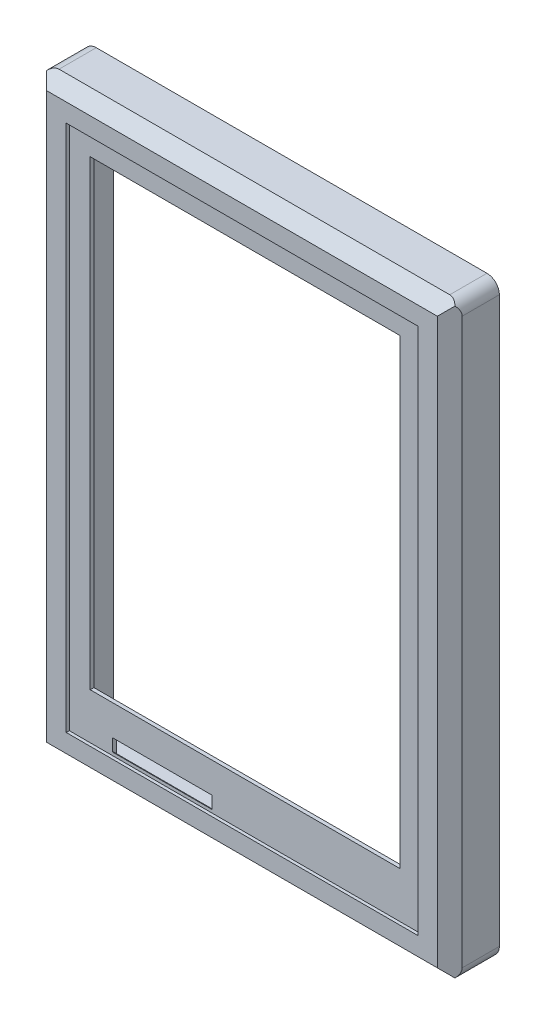
from build123d import *

# Parameters (mm, degrees)
SKIZZE1_W                        = 67
SKIZZE1_H                        = 95
AUFSATZ_LINEAR_AUSTRAGEN1_DEPTH  = 8
SKIZZE2_W                        = 56.7
SKIZZE2_H                        = 85.1
SCHNITT_LINEAR_AUSTRAGEN1_DEPTH  = 0.5
SCHNITT_LINEAR_START             = -7.5
SKIZZE3_W                        = 49.96
SKIZZE3_H                        = 74.44
SCHNITT_LINEAR_AUSTRAGEN2_DEPTH  = 7.5
SCHNITT_LINEAR_AUSTRAGEN3_REACH  = 9.5
SKIZZE4_W                        = 16
SKIZZE4_H                        = 2
SKIZZE5_W                        = 56.8
SKIZZE5_H                        = 85.3
SCHNITT_LINEAR_AUSTRAGEN4_DEPTH  = 6.9
FASE1_SIZE                       = 2
FASE2_SIZE                       = 0.5
SKIZZE8_W                        = 56.8
SKIZZE8_H                        = 3
SCHNITT_LINEAR_AUSTRAGEN5_DEPTH  = 2
SKIZZE10_W                       = 56.8
SKIZZE10_H                       = 1.5
AUFSATZ_LINEAR_AUSTRAGEN2_DEPTH  = 85.3
SCHNITT_LINEAR_AUSTRAGEN6_REACH  = 7.6
SKIZZE12_W                       = 56.8
SKIZZE12_H                       = 82.3
VERRUNDUNG2_R                    = 2
FASE3_SIZE                       = 3
FASE3_SIZE2                      = 0.803847577
SCHNITT_LINEAR_AUSTRAGEN9_DEPTH  = 3
FASE8_SIZE                       = 0.3
SKIZZE18_W                       = 1.65
SKIZZE18_H                       = 4.4
SCHNITT_LINEAR_AUSTRAGEN10_DEPTH = 4.1
AUFSATZ_LINEAR_START             = 1.65
SKIZZE20_R                       = 1.75
AUFSATZ_LINEAR_AUSTRAGEN7_DEPTH  = 4
SCHNITT_LINEAR_START_2           = -1
SKIZZE21_R                       = 1.05
SCHNITT_LINEAR_AUSTRAGEN12_DEPTH = 6.65
LINEARES_MUSTER1_COUNT           = 2
LINEARES_MUSTER1_PITCH           = 68.8
LINEARES_START                   = 1.65
LINEARES_MUSTER1_COPY_1_SKETCH_R = 1.75
LINEARES_MUSTER1_COPY_1_DEPTH    = 4
LINEARES_START_2                 = -1
LINEARES_MUSTER1_COPY_2_SKETCH_R = 1.05
LINEARES_MUSTER1_COPY_2_DEPTH    = 6.65
LINEARES_MUSTER1_COPY_3_SKETCH_W = 1.65
LINEARES_MUSTER1_COPY_3_SKETCH_H = 4.4
LINEARES_MUSTER1_COPY_3_DEPTH    = 4.1


with BuildPart() as part:
    # Skizze1 → Aufsatz-Linear austragen1 (new body)
    with BuildSketch(Plane.XY):
        with Locations((33.5, 47.5)):
            Rectangle(SKIZZE1_W, SKIZZE1_H)
    extrude(amount=AUFSATZ_LINEAR_AUSTRAGEN1_DEPTH)

    # Skizze2 → Schnitt-Linear austragen1 (cut)
    with BuildSketch(Plane.XY.offset(8)):
        with Locations((33.5, 47.5)):
            Rectangle(SKIZZE2_W, SKIZZE2_H)
    extrude(amount=-SCHNITT_LINEAR_AUSTRAGEN1_DEPTH, mode=Mode.SUBTRACT)

    # Skizze3 → Schnitt-Linear austragen2 (cut)
    with BuildSketch(Plane.XY.offset(7.5).offset(SCHNITT_LINEAR_START)):
        with Locations((33.5, 49.57)):
            Rectangle(SKIZZE3_W, SKIZZE3_H)
    extrude(amount=SCHNITT_LINEAR_AUSTRAGEN2_DEPTH, mode=Mode.SUBTRACT)

    # Skizze4 → Schnitt-Linear austragen3 (cut, up to next)
    with BuildSketch(Plane.XY.offset(7.5), mode=Mode.PRIVATE) as schnitt_linear_austragen3_sk1:
        with Locations((20.15, 6.45)):
            Rectangle(SKIZZE4_W, SKIZZE4_H)
    schnitt_linear_austragen3_tool1 = extrude(schnitt_linear_austragen3_sk1.sketch, amount=-SCHNITT_LINEAR_AUSTRAGEN3_REACH, mode=Mode.PRIVATE) & part.part
    add(schnitt_linear_austragen3_tool1.solids().sort_by_distance((20.15, 6.45, 7.5))[0], mode=Mode.SUBTRACT)

    # Skizze5 → Schnitt-Linear austragen4 (cut)
    with BuildSketch(Plane(origin=(0, 0, 0), x_dir=(-1, 0, 0), z_dir=(0, 0, -1))):
        with Locations((-33.5, 47.5)):
            Rectangle(SKIZZE5_W, SKIZZE5_H)
    extrude(amount=-SCHNITT_LINEAR_AUSTRAGEN4_DEPTH, mode=Mode.SUBTRACT)

    # Fase1
    fase1_edges = [part.edges().sort_by_distance(p)[0] for p in [
        (67, 47.5, 8),
        (33.5, 95, 8),
        (0, 47.5, 8),
        (33.5, 0, 8),
    ]]
    chamfer(fase1_edges, length=FASE1_SIZE)

    # Fase2
    fase2_edges = [part.edges().sort_by_distance(p)[0] for p in [
        (20.15, 5.45, 6.9),
    ]]
    chamfer(fase2_edges, length=FASE2_SIZE)

    # Skizze8 → Schnitt-Linear austragen5 (cut)
    with BuildSketch(Plane.XZ.offset(-90.15)):
        with Locations((33.5, 5.4)):
            Rectangle(SKIZZE8_W, SKIZZE8_H)
    extrude(amount=-SCHNITT_LINEAR_AUSTRAGEN5_DEPTH, mode=Mode.SUBTRACT)

    # Skizze10 → Aufsatz-Linear austragen2 (add)
    with BuildSketch(Plane.XZ.offset(-90.15)):
        with Locations((33.5, 3.15)):
            Rectangle(SKIZZE10_W, SKIZZE10_H)
    extrude(amount=AUFSATZ_LINEAR_AUSTRAGEN2_DEPTH)

    # Skizze12 → Schnitt-Linear austragen6 (cut, up to next)
    with BuildSketch(Plane(origin=(0, 0, 2.4), x_dir=(-1, 0, 0), z_dir=(0, 0, -1)), mode=Mode.PRIVATE) as schnitt_linear_austragen6_sk1:
        with Locations((-33.5, 47.5)):
            Rectangle(SKIZZE12_W, SKIZZE12_H)
    schnitt_linear_austragen6_tool1 = extrude(schnitt_linear_austragen6_sk1.sketch, amount=-SCHNITT_LINEAR_AUSTRAGEN6_REACH, mode=Mode.PRIVATE) & part.part
    add(schnitt_linear_austragen6_tool1.solids().sort_by_distance((33.5, 47.5, 2.4))[0], mode=Mode.SUBTRACT)

    # Verrundung2
    verrundung2_edges = [part.edges().sort_by_distance(p)[0] for p in [
        (0, 0, 3),
        (0, 95, 3),
        (67, 0, 3),
        (67, 95, 3),
    ]]
    fillet(verrundung2_edges, radius=VERRUNDUNG2_R)

    # Fase3
    fase3_edges = [part.edges().sort_by_distance(p)[0] for p in [
        (33.5, 88.65, 3.9),
    ]]
    fase3_side = [part.faces().sort_by_distance(p)[0] for p in [
        (33.5, 90.4, 3.9),
    ]]
    chamfer(fase3_edges, length=FASE3_SIZE, length2=FASE3_SIZE2, reference=fase3_side[0])

    # Skizze14 → Schnitt-Linear austragen9 (cut)
    with BuildSketch(Plane(origin=(0, 0, 0), x_dir=(-1, 0, 0), z_dir=(0, 0, -1))):
        with BuildLine():
            Line((-64, 94), (-3, 94))
            ThreePointArc((-3, 94), (-1.585786438, 93.414213562), (-1, 92))
            Line((-1, 92), (-1, 3))
            ThreePointArc((-1, 3), (-1.585786438, 1.585786438), (-3, 1))
            Line((-3, 1), (-64, 1))
            ThreePointArc((-64, 1), (-65.414213562, 1.585786438), (-66, 3))
            Line((-66, 3), (-66, 92))
            ThreePointArc((-66, 92), (-65.414213562, 93.414213562), (-64, 94))
        make_face()
        with BuildLine():
            ThreePointArc((-64.8, 4.2), (-64.214213562, 2.785786438), (-62.8, 2.2))
            Line((-62.8, 2.2), (-4.2, 2.2))
            ThreePointArc((-4.2, 2.2), (-2.785786438, 2.785786438), (-2.2, 4.2))
            Line((-2.2, 4.2), (-2.2, 90.8))
            ThreePointArc((-2.2, 90.8), (-2.785786438, 92.214213562), (-4.2, 92.8))
            Line((-4.2, 92.8), (-62.8, 92.8))
            ThreePointArc((-62.8, 92.8), (-64.214213562, 92.214213562), (-64.8, 90.8))
            Line((-64.8, 90.8), (-64.8, 4.2))
        make_face(mode=Mode.SUBTRACT)
    extrude(amount=-SCHNITT_LINEAR_AUSTRAGEN9_DEPTH, mode=Mode.SUBTRACT)

    # Fase8
    fase8_edges = [part.edges().sort_by_distance(p)[0] for p in [
        (64.214213562, 2.785786438, 0),
        (33.5, 2.2, 0),
        (2.2, 47.5, 0),
        (2.785786438, 92.214213562, 0),
        (64.214213562, 92.214213562, 0),
        (64.8, 47.5, 0),
        (33.5, 92.8, 0),
        (2.785786438, 2.785786438, 0),
        (61.9, 47.5, 0),
        (33.5, 4.85, 0),
        (5.1, 47.5, 0),
        (33.5, 90.15, 0),
    ]]
    chamfer(fase8_edges, length=FASE8_SIZE)

    # Skizze18 → Schnitt-Linear austragen10 (cut)
    with BuildSketch(Plane(origin=(5.1, 0, 0), x_dir=(0, 0, -1), z_dir=(1, 0, 0))):
        with Locations((-4.825, 80.8)):
            Rectangle(SKIZZE18_W, SKIZZE18_H)
    schnitt_linear_austragen10 = extrude(amount=-SCHNITT_LINEAR_AUSTRAGEN10_DEPTH, mode=Mode.SUBTRACT)

    # Spiegeln6: Schnitt-Linear austragen10 across plane
    add(schnitt_linear_austragen10.mirror(Plane.ZY.offset(-33.5)), mode=Mode.SUBTRACT)

    # Skizze20 → Aufsatz-Linear austragen7 (add)
    with BuildSketch(Plane(origin=(0, 0, 5.65), x_dir=(-1, 0, 0), z_dir=(0, 0, -1)).offset(AUFSATZ_LINEAR_START)):
        with Locations((-3, 80.8)):
            Circle(SKIZZE20_R)
    aufsatz_linear_austragen7 = extrude(amount=AUFSATZ_LINEAR_AUSTRAGEN7_DEPTH)

    # Skizze21 → Schnitt-Linear austragen12 (cut)
    with BuildSketch(Plane(origin=(0, 0, 5.65), x_dir=(-1, 0, 0), z_dir=(0, 0, -1)).offset(SCHNITT_LINEAR_START_2)):
        with Locations((-3, 80.8)):
            Circle(SKIZZE21_R)
    schnitt_linear_austragen12 = extrude(amount=SCHNITT_LINEAR_AUSTRAGEN12_DEPTH, mode=Mode.SUBTRACT)

    # Spiegeln1: Aufsatz-Linear austragen7, Schnitt-Linear austragen12 across plane
    add(aufsatz_linear_austragen7.mirror(Plane.ZY.offset(-33.5)))
    add(schnitt_linear_austragen12.mirror(Plane.ZY.offset(-33.5)), mode=Mode.SUBTRACT)

    # Lineares Muster1: Schnitt-Linear austragen10, Aufsatz-Linear austragen7, Schnitt-Linear austragen12 ×2
    with Locations(*[(0, -i * LINEARES_MUSTER1_PITCH, 0) for i in range(1, LINEARES_MUSTER1_COUNT)]):
        add(schnitt_linear_austragen10, mode=Mode.SUBTRACT)
        add(aufsatz_linear_austragen7)
        add(schnitt_linear_austragen12, mode=Mode.SUBTRACT)

    # Lineares Muster1 copy 1 sketch → Lineares Muster1 copy 1 (add)
    with BuildSketch(Plane(origin=(67, -68.8, 5.65), x_dir=(1, 0, 0), z_dir=(0, 0, -1)).offset(LINEARES_START)):
        with Locations((-3, -80.8)):
            Circle(LINEARES_MUSTER1_COPY_1_SKETCH_R)
    extrude(amount=LINEARES_MUSTER1_COPY_1_DEPTH)

    # Lineares Muster1 copy 2 sketch → Lineares Muster1 copy 2 (cut)
    with BuildSketch(Plane(origin=(67, -68.8, 5.65), x_dir=(1, 0, 0), z_dir=(0, 0, -1)).offset(LINEARES_START_2)):
        with Locations((-3, -80.8)):
            Circle(LINEARES_MUSTER1_COPY_2_SKETCH_R)
    extrude(amount=LINEARES_MUSTER1_COPY_2_DEPTH, mode=Mode.SUBTRACT)

    # Lineares Muster1 copy 3 sketch → Lineares Muster1 copy 3 (cut)
    with BuildSketch(Plane(origin=(61.9, -68.8, 0), x_dir=(0, 0, -1), z_dir=(-1, 0, 0))):
        with Locations((-4.825, -80.8)):
            Rectangle(LINEARES_MUSTER1_COPY_3_SKETCH_W, LINEARES_MUSTER1_COPY_3_SKETCH_H)
    extrude(amount=-LINEARES_MUSTER1_COPY_3_DEPTH, mode=Mode.SUBTRACT)


solid = part.part
